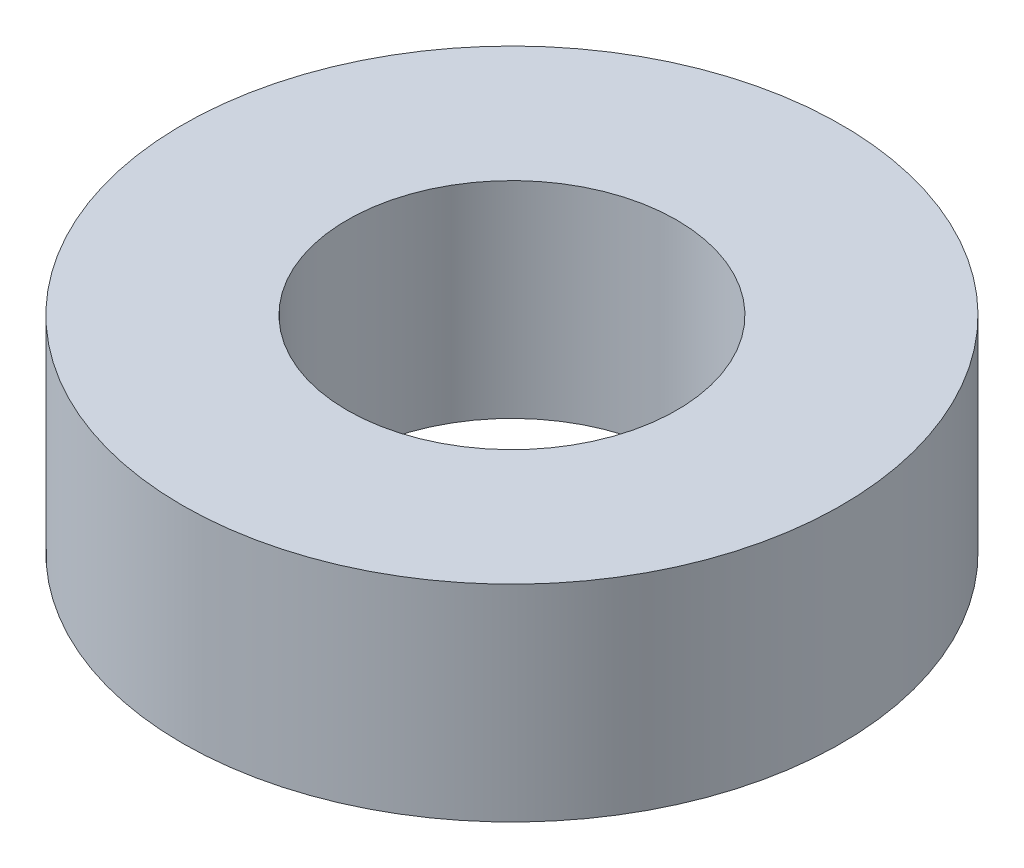
from build123d import *

# Parameters (mm, degrees)
SKETCH1_R           = 8
BOSS_EXTRUDE1_DEPTH = 5
SKETCH2_R           = 4
CUT_EXTRUDE1_DEPTH  = 5


with BuildPart() as part:
    # Sketch1 → Boss-Extrude1 (new body)
    with BuildSketch(Plane(origin=(0, 0, 0), x_dir=(1, 0, 0), z_dir=(0, 1, 0))):
        Circle(SKETCH1_R)
    extrude(amount=BOSS_EXTRUDE1_DEPTH)

    # Sketch2 → Cut-Extrude1 (cut)
    with BuildSketch(Plane(origin=(0, 5, 0), x_dir=(1, 0, 0), z_dir=(0, 1, 0))):
        Circle(SKETCH2_R)
    extrude(amount=-CUT_EXTRUDE1_DEPTH, mode=Mode.SUBTRACT)


solid = part.part
